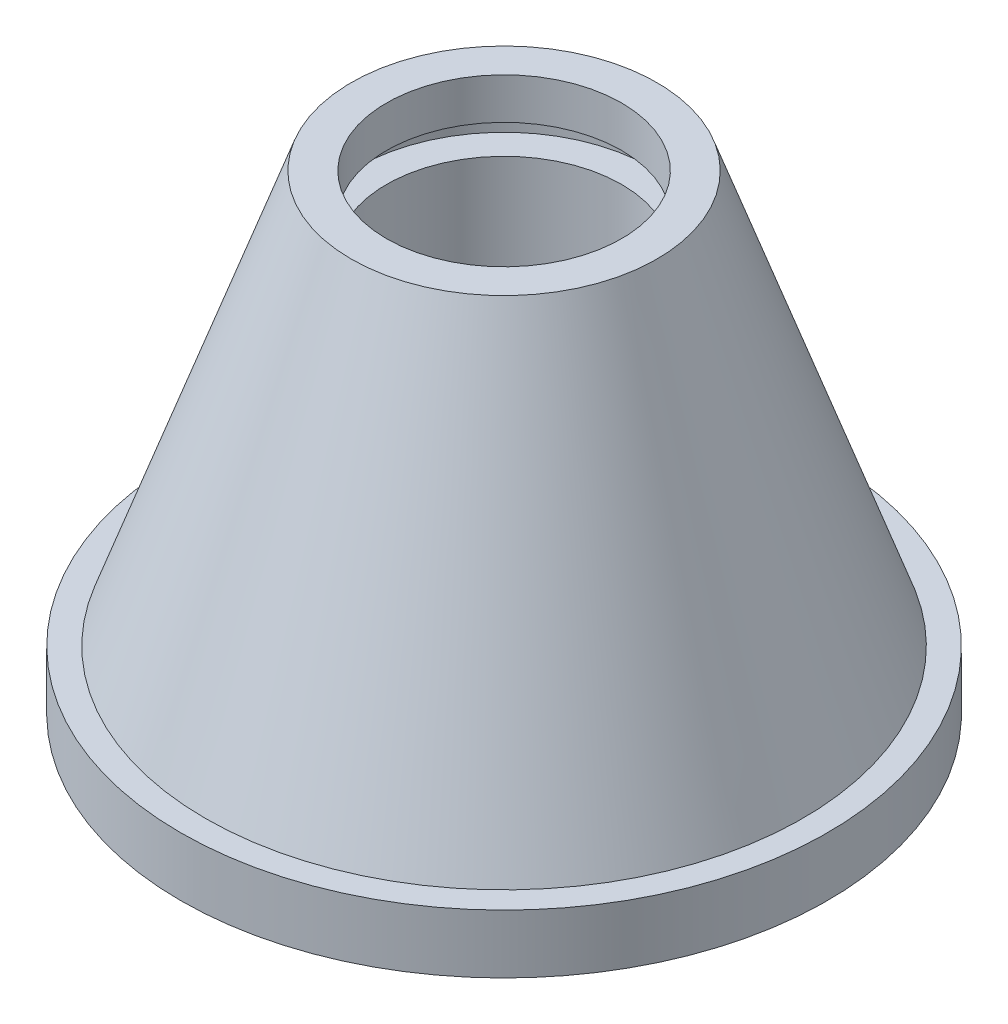
from build123d import *


with BuildPart() as part:
    # Sketch1 → Revolve1 (revolve)
    with BuildSketch(Plane.XY):
        Polygon((-55, 0), (-35, 0), (-35, 33), (-20, 33), (-20, 68), (-25, 68), (-25, 73), (-20, 73), (-20, 80), (-26, 80), (-50.784671533, 10), (-55, 10), align=None)
    revolve(axis=Axis((0, 128.229147948, 0), (0, -1, 0)))


solid = part.part
